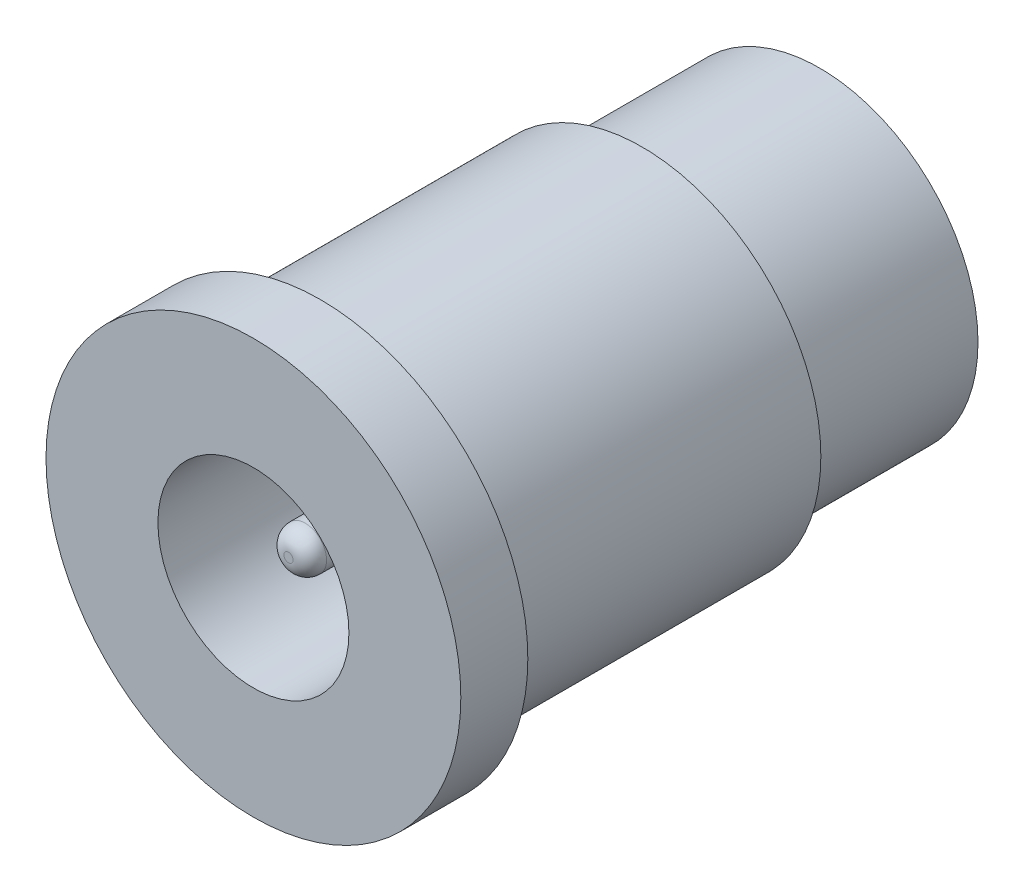
from build123d import *


with BuildPart() as part:
    # Sketch1 → Revolve1 (revolve)
    with BuildSketch(Plane(origin=(0, 0, 0), x_dir=(0, 0, -1), z_dir=(1, 0, 0))):
        with BuildLine():
            Line((0, 2.85), (0, 6.19))
            Line((0, 6.19), (2, 6.19))
            Line((2, 6.19), (2, 5.335))
            Line((2, 5.335), (11.6, 5.335))
            Line((11.6, 5.335), (11.6, 4.725))
            Line((11.6, 4.725), (16.9, 4.725))
            Line((16.9, 4.725), (16.9, 0))
            Line((16.9, 0), (1.046838235, 0))
            Line((1.046838235, 0), (1.046838235, 0.137205882))
            ThreePointArc((1.046838235, 0.137205882), (1.193284845, 0.490759273), (1.546838235, 0.637205882))
            Line((1.546838235, 0.637205882), (11.6, 0.637205882))
            Line((11.6, 0.637205882), (11.6, 2.85))
            Line((11.6, 2.85), (0, 2.85))
        make_face()
    revolve(axis=Axis((0, 0, 5.006617647), (0, 0, -1)))


solid = part.part
